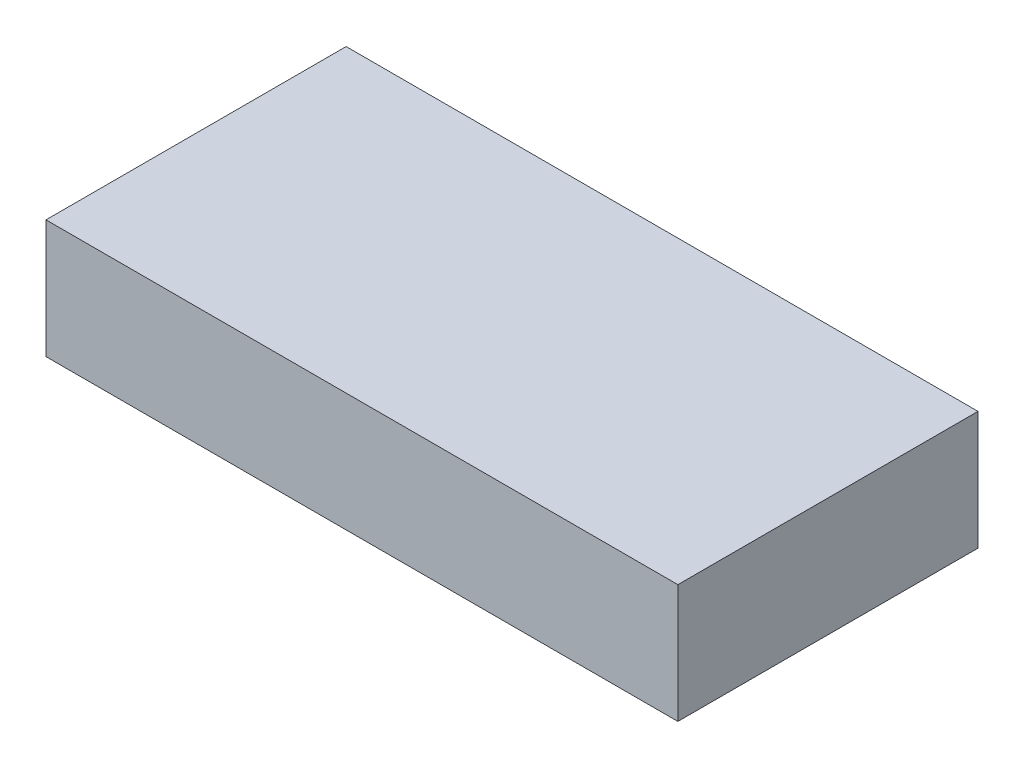
from build123d import *

# Parameters (mm, degrees)
SKETCH1_W           = 80
SKETCH1_H           = 38
BOSS_EXTRUDE1_DEPTH = 15


with BuildPart() as part:
    # Sketch1 → Boss-Extrude1 (new body)
    with BuildSketch(Plane(origin=(0, 0, 0), x_dir=(1, 0, 0), z_dir=(0, 1, 0))):
        with Locations((-40, -19)):
            Rectangle(SKETCH1_W, SKETCH1_H)
    extrude(amount=BOSS_EXTRUDE1_DEPTH)


solid = part.part
